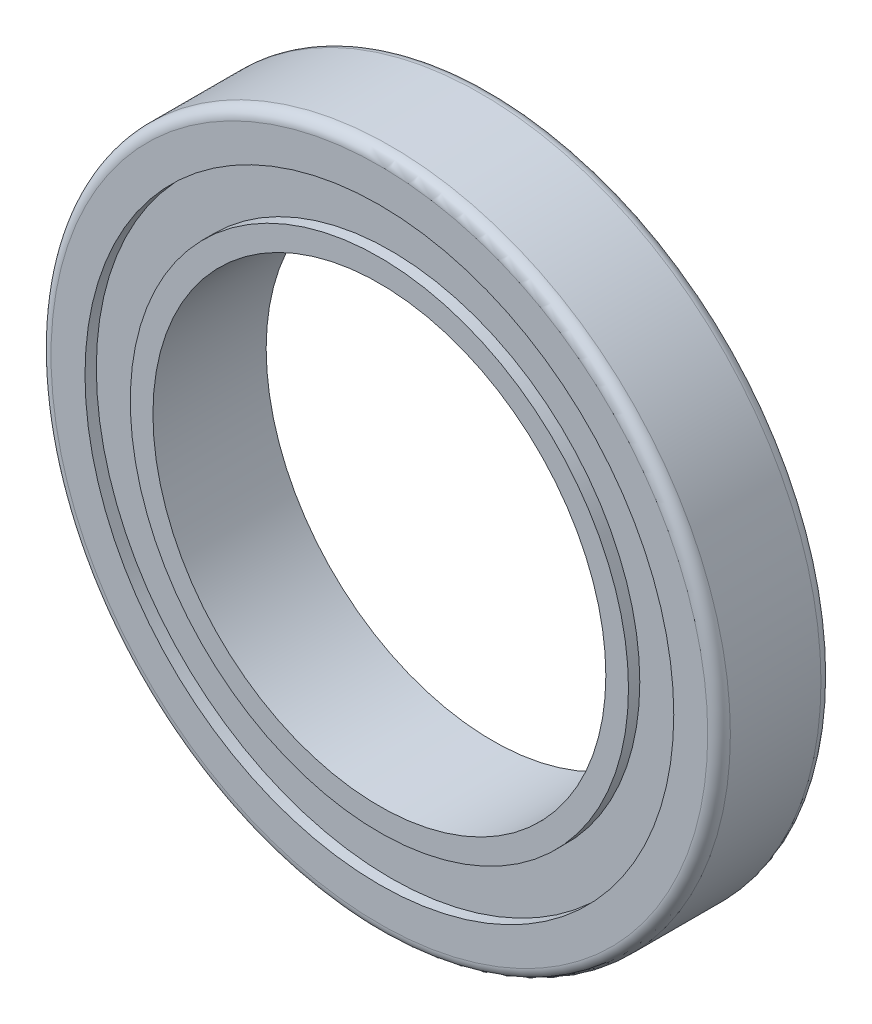
from build123d import *

# Parameters (mm, degrees)
SKETCH1_R           = 15
SKETCH1_R_2         = 10
BOSS_EXTRUDE1_DEPTH = 5
FILLET1_R           = 0.5
SKETCH2_R           = 13
SKETCH2_R_2         = 11
CUT_EXTRUDE1_DEPTH  = 0.5
SKETCH3_R           = 13
SKETCH3_R_2         = 11
CUT_EXTRUDE2_DEPTH  = 0.5


with BuildPart() as part:
    # Sketch1 → Boss-Extrude1 (new body)
    with BuildSketch(Plane.XY):
        with Locations((0, 1.584180911)):
            Circle(SKETCH1_R)
        with Locations((0, 1.584180911)):
            Circle(SKETCH1_R_2, mode=Mode.SUBTRACT)
    extrude(amount=BOSS_EXTRUDE1_DEPTH)

    # Fillet1
    fillet1_edges = [part.edges().sort_by_distance(p)[0] for p in [
        (-15, 1.584180911, 0),
        (-15, 1.584180911, 5),
    ]]
    fillet(fillet1_edges, radius=FILLET1_R)

    # Sketch2 → Cut-Extrude1 (cut)
    with BuildSketch(Plane.XY.offset(5)):
        with Locations((0, 1.584180911)):
            Circle(SKETCH2_R)
        with Locations((0, 1.584180911)):
            Circle(SKETCH2_R_2, mode=Mode.SUBTRACT)
    extrude(amount=-CUT_EXTRUDE1_DEPTH, mode=Mode.SUBTRACT)

    # Sketch3 → Cut-Extrude2 (cut)
    with BuildSketch(Plane(origin=(0, 0, 0), x_dir=(-1, 0, 0), z_dir=(0, 0, -1))):
        with Locations((0, 1.584180911)):
            Circle(SKETCH3_R)
        with Locations((0, 1.584180911)):
            Circle(SKETCH3_R_2, mode=Mode.SUBTRACT)
    extrude(amount=-CUT_EXTRUDE2_DEPTH, mode=Mode.SUBTRACT)


solid = part.part
